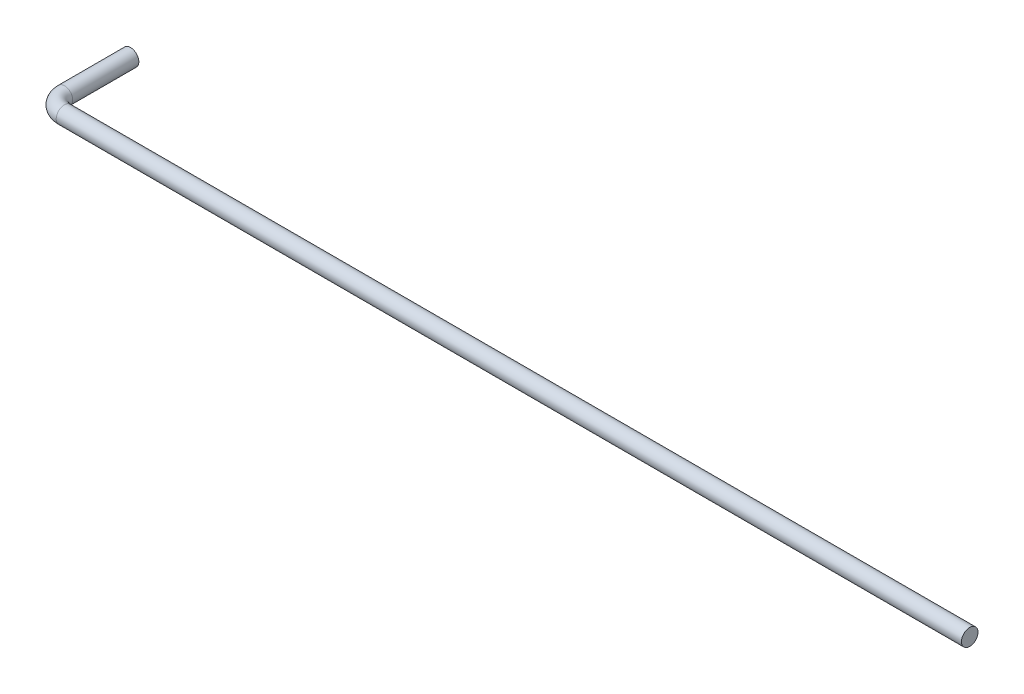
from build123d import *

# Parameters (mm, degrees)
SWEEP_1_PROFILE_R = 1


with BuildPart() as part:
    # 스윕1: sweep along a path in 스케치1
    with BuildLine(Plane(origin=(0, 0, 0), x_dir=(1, 0, 0), z_dir=(0, 1, 0))) as sweep_1_path:
        Line((55.114367542, 0), (-54.445632458, 0))
        ThreePointArc((-54.445632458, 0), (-55.859846021, 0.585786438), (-56.445632458, 2))
        Line((-56.445632458, 2), (-56.445632458, 10))
    # 스윕1 profile (on start of the path) → 스윕1 (sweep)
    with BuildSketch(Plane(origin=(55.114367542, 0, 0), x_dir=(0, 0, -1), z_dir=(-1, 0, 0))):
        Circle(SWEEP_1_PROFILE_R)
    sweep(path=sweep_1_path.line)


solid = part.part
